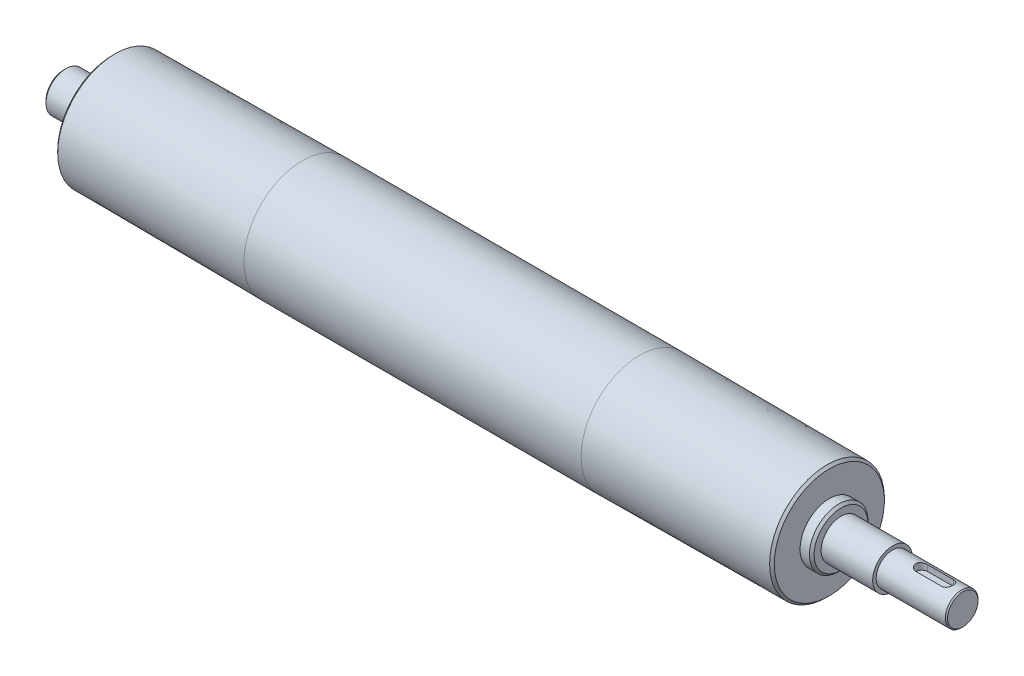
from build123d import *

# Parameters (mm, degrees)
EXTRUDE1_DEPTH = 22


with BuildPart() as part:
    # Sketch1 → Revolve1 (revolve)
    with BuildSketch(Plane(origin=(0, 0, 0), x_dir=(1, 0, 0), z_dir=(0, 1, 0)), mode=Mode.PRIVATE) as revolve1_sk:
        Polygon((-72, 25), (72, 25), (152, 24.5), (153, 23.5), (153, 12.5), (157, 12.5), (158, 11.5), (158, 8.5), (180, 8.5), (180, 7), (209.5, 7), (210, 6.5), (210, 0), (-174, 0), (-174, 7.5), (-173, 8.5), (-158, 8.5), (-158, 11.5), (-157, 12.5), (-153, 12.5), (-153, 23.5), (-152, 24.5), align=None)
    revolve(revolve1_sk.sketch.rotate(Axis((-174, 0, 0), (1, 0, 0)), 180), axis=Axis((-174, 0, 0), (1, 0, 0)))  # turned: the seam where the file's is

    # Sketch2 → Extrude1 (cut, through all)
    with BuildSketch(Plane(origin=(0, 4, 0), x_dir=(-1, 0, 0), z_dir=(0, 1, 0))):
        with BuildLine():
            Line((-203.5, 2.5), (-192.5, 2.5))
            ThreePointArc((-192.5, 2.5), (-190, 0), (-192.5, -2.5))
            Line((-192.5, -2.5), (-203.5, -2.5))
            ThreePointArc((-203.5, -2.5), (-206, 0), (-203.5, 2.5))
        make_face()
    extrude(amount=EXTRUDE1_DEPTH, mode=Mode.SUBTRACT)


solid = part.part
